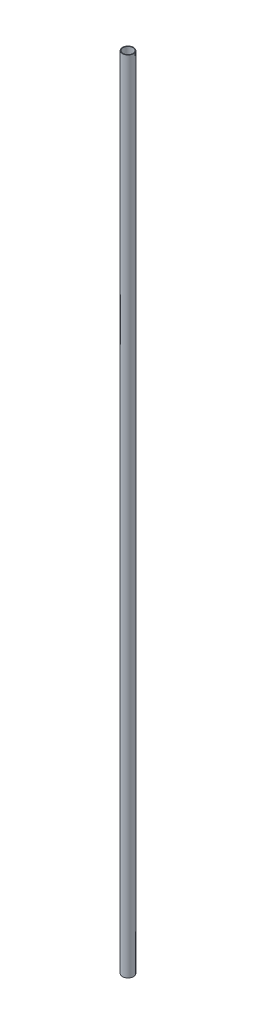
from build123d import *

# Parameters (mm, degrees)
SKETCH1_R           = 14.7701
SKETCH1_R_2         = 13.3223
BOSS_EXTRUDE1_DEPTH = 2133.6


with BuildPart() as part:
    # Sketch1 → Boss-Extrude1 (new body)
    with BuildSketch(Plane(origin=(0, 0, 0), x_dir=(1, 0, 0), z_dir=(0, 1, 0))):
        Circle(SKETCH1_R)
        Circle(SKETCH1_R_2, mode=Mode.SUBTRACT)
    extrude(amount=BOSS_EXTRUDE1_DEPTH)


solid = part.part
